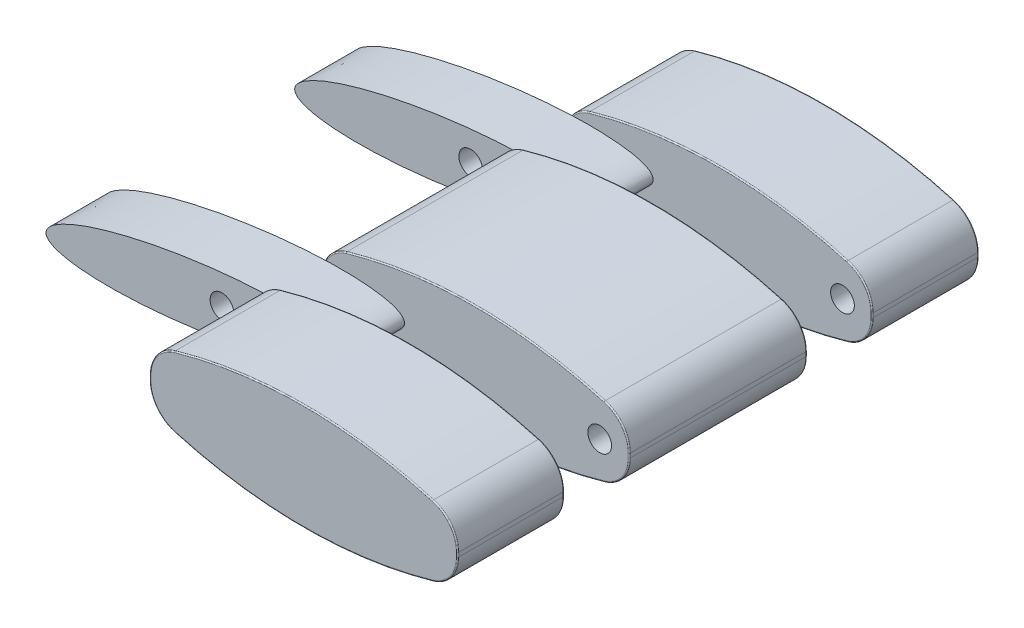
from build123d import *

# Parameters (mm, degrees)
BOSS_EXTRUDE1_DEPTH = 22
SKETCH2_W           = 20.821066257
SKETCH2_H           = 2.75
SKETCH2_W_2         = 22.326203578
CUT_EXTRUDE1_DEPTH  = 11
CUT_EXTRUDE2_START  = -0.5
SKETCH3_R           = 0.5
CUT_EXTRUDE2_DEPTH  = 21
FILLET1_R           = 0.05
FILLET2_R           = 0.05
FILLET3_R           = 0.05
SKETCH4_R           = 0.5
CUT_EXTRUDE3_DEPTH  = 30
BOSS_EXTRUDE2_START = -4.5
SKETCH6_RX          = 6.381317706
SKETCH6_RY          = 1.230977933
BOSS_EXTRUDE2_DEPTH = 2.5
BOSS_EXTRUDE3_START = -17.5
SKETCH6_2_RX        = 6.381317706
SKETCH6_2_RY        = 1.230977933
BOSS_EXTRUDE3_DEPTH = 2.5
SKETCH7_R           = 0.5
CUT_EXTRUDE6_DEPTH  = 22.5
SKETCH9_R           = 0.642655751
BOSS_EXTRUDE4_DEPTH = 0.5
SKETCH10_R          = 0.749250698
BOSS_EXTRUDE5_DEPTH = 0.5


with BuildPart() as part:
    # Sketch1 → Boss-Extrude1 (new body)
    with BuildSketch(Plane.XY):
        with BuildLine():
            Line((-6.5, 0.089598011), (-6.5, -0.089598011))
            ThreePointArc((-6.5, -0.089598011), (-6.208135141, -0.962078954), (-5.450037249, -1.483323307))
            ThreePointArc((-5.450037249, -1.483323307), (0, -2.25), (5.450037249, -1.483323307))
            ThreePointArc((5.450037249, -1.483323307), (6.208135141, -0.962078954), (6.5, -0.089598011))
            Line((6.5, -0.089598011), (6.5, 0.089598011))
            ThreePointArc((6.5, 0.089598011), (6.208135141, 0.962078954), (5.450037249, 1.483323307))
            ThreePointArc((5.450037249, 1.483323307), (0, 2.25), (-5.450037249, 1.483323307))
            ThreePointArc((-5.450037249, 1.483323307), (-6.208135141, 0.962078954), (-6.5, 0.089598011))
        make_face()
    extrude(amount=BOSS_EXTRUDE1_DEPTH)

    # Sketch2 → Cut-Extrude1 (cut, symmetric)
    with BuildSketch(Plane(origin=(0, 0, 0), x_dir=(1, 0, 0), z_dir=(0, 1, 0))):
        with Locations((-0.407641358, -5.875)):
            Rectangle(SKETCH2_W, SKETCH2_H)
        with Locations((1.37970921, -16.125)):
            Rectangle(SKETCH2_W_2, SKETCH2_H)
    extrude(amount=CUT_EXTRUDE1_DEPTH, both=True, mode=Mode.SUBTRACT)


with BuildPart() as cut_extrude1_piece_1:
    # of the separate pieces the step leaves, piece 1, a body of its own (cut_extrude1_pieces)
    add(part.part.solids().sort_by_distance((6.5, -0.089598011, 7.25))[0])


with BuildPart() as cut_extrude1_piece_2:
    # of the separate pieces the step leaves, piece 2, a body of its own (cut_extrude1_pieces)
    add(part.part.solids().sort_by_distance((6.5, -0.089598011, 17.5))[0])


with BuildPart() as cut_extrude1_piece_3:
    # of the separate pieces the step leaves, piece 3, a body of its own (cut_extrude1_pieces)
    add(part.part.solids().sort_by_distance((5.450037249, -1.483323307, 0))[0])


with BuildPart() as cut_extrude2_tool:
    # Sketch3 → Cut-Extrude2 (new body)
    with BuildSketch(Plane.XY.offset(22).offset(CUT_EXTRUDE2_START)):
        with Locations((5.25, 0)):
            Circle(SKETCH3_R)
        with Locations((-5.25, 0)):
            Circle(SKETCH3_R)
    extrude(amount=-CUT_EXTRUDE2_DEPTH)


with BuildPart() as cut_extrude1_piece_1_1:
    add(cut_extrude1_piece_1.part)

    # Cut-Extrude2: cut by cut_extrude2_tool
    add(cut_extrude2_tool.part, mode=Mode.SUBTRACT)

    # Fillet2
    fillet2_edges = [cut_extrude1_piece_1_1.edges().sort_by_distance(p)[0] for p in [
        (6.208135141, 0.962078954, 7.25),
        (6.5, 0, 7.25),
        (6.208135141, -0.962078954, 7.25),
        (0, -2.25, 7.25),
        (-6.208135141, -0.962078954, 7.25),
        (-6.5, 0, 7.25),
        (-6.208135141, 0.962078954, 7.25),
        (-6.208135141, 0.962078954, 14.75),
        (-6.5, 0, 14.75),
        (-6.208135141, -0.962078954, 14.75),
        (0, -2.25, 14.75),
        (6.208135141, -0.962078954, 14.75),
        (6.5, 0, 14.75),
        (6.208135141, 0.962078954, 14.75),
        (0, 2.25, 7.25),
        (0, 2.25, 14.75),
    ]]
    fillet(fillet2_edges, radius=FILLET2_R)


with BuildPart() as cut_extrude1_piece_2_1:
    add(cut_extrude1_piece_2.part)

    # Cut-Extrude2: cut by cut_extrude2_tool
    add(cut_extrude2_tool.part, mode=Mode.SUBTRACT)

    # Fillet1
    fillet1_edges = [cut_extrude1_piece_2_1.edges().sort_by_distance(p)[0] for p in [
        (6.208135141, 0.962078954, 17.5),
        (6.5, 0, 17.5),
        (6.208135141, -0.962078954, 17.5),
        (0, -2.25, 17.5),
        (-6.208135141, -0.962078954, 17.5),
        (-6.5, 0, 17.5),
        (-6.208135141, 0.962078954, 17.5),
        (6.5, 0, 22),
        (6.208135141, -0.962078954, 22),
        (0, -2.25, 22),
        (-6.208135141, -0.962078954, 22),
        (-6.5, 0, 22),
        (-6.208135141, 0.962078954, 22),
        (0, 2.25, 22),
        (6.208135141, 0.962078954, 22),
        (0, 2.25, 17.5),
    ]]
    fillet(fillet1_edges, radius=FILLET1_R)


with BuildPart() as cut_extrude1_piece_3_1:
    add(cut_extrude1_piece_3.part)

    # Cut-Extrude2: cut by cut_extrude2_tool
    add(cut_extrude2_tool.part, mode=Mode.SUBTRACT)

    # Fillet3
    fillet3_edges = [cut_extrude1_piece_3_1.edges().sort_by_distance(p)[0] for p in [
        (6.208135141, 0.962078954, 0),
        (6.5, 0, 0),
        (6.208135141, -0.962078954, 0),
        (0, -2.25, 0),
        (-6.208135141, -0.962078954, 0),
        (-6.5, 0, 0),
        (-6.208135141, 0.962078954, 0),
        (-6.5, 0, 4.5),
        (-6.208135141, -0.962078954, 4.5),
        (0, -2.25, 4.5),
        (6.208135141, -0.962078954, 4.5),
        (6.5, 0, 4.5),
        (6.208135141, 0.962078954, 4.5),
        (0, 2.25, 4.5),
        (0, 2.25, 0),
        (-6.208135141, 0.962078954, 4.5),
    ]]
    fillet(fillet3_edges, radius=FILLET3_R)


with BuildPart() as cut_extrude3_tool:
    # Sketch4 → Cut-Extrude3 (new, symmetric)
    with BuildSketch(Plane.XY.offset(4.5)):
        with Locations((5.25, 0)):
            Circle(SKETCH4_R)
    extrude(amount=CUT_EXTRUDE3_DEPTH, both=True)


with BuildPart() as cut_extrude1_piece_2_2:
    add(cut_extrude1_piece_2_1.part)

    # Cut-Extrude3: cut by cut_extrude3_tool
    add(cut_extrude3_tool.part, mode=Mode.SUBTRACT)

    # Sketch6 → Boss-Extrude2 (add)
    with BuildSketch(Plane.XY.offset(22).offset(BOSS_EXTRUDE2_START)):
        with Locations(Location((-9.058816325, -0.515837668), (0, 0, 8.239325628))):
            Ellipse(SKETCH6_RX, SKETCH6_RY)
    extrude(amount=-BOSS_EXTRUDE2_DEPTH)


with BuildPart() as cut_extrude1_piece_3_2:
    add(cut_extrude1_piece_3_1.part)

    # Cut-Extrude3: cut by cut_extrude3_tool
    add(cut_extrude3_tool.part, mode=Mode.SUBTRACT)

    # Sketch6_2 → Boss-Extrude3 (add)
    with BuildSketch(Plane.XY.offset(22).offset(BOSS_EXTRUDE3_START)):
        with Locations(Location((-9.058816325, -0.515837668), (0, 0, 8.239325628))):
            Ellipse(SKETCH6_2_RX, SKETCH6_2_RY)
    extrude(amount=BOSS_EXTRUDE3_DEPTH)


with BuildPart() as cut_extrude6_tool:
    # Sketch7 → Cut-Extrude6 (new body)
    with BuildSketch(Plane.XY.offset(17.5)):
        with Locations((-7.947567337, -0.377382917)):
            Circle(SKETCH7_R)
    extrude(amount=-CUT_EXTRUDE6_DEPTH)


with BuildPart() as cut_extrude1_piece_2_3:
    add(cut_extrude1_piece_2_2.part)

    # Cut-Extrude6: cut by cut_extrude6_tool
    add(cut_extrude6_tool.part, mode=Mode.SUBTRACT)

    # Sketch9 → Boss-Extrude4 (add)
    with BuildSketch(Plane.XY.offset(22)):
        with Locations((5.25, 0)):
            Circle(SKETCH9_R)
    extrude(amount=-BOSS_EXTRUDE4_DEPTH)


with BuildPart() as cut_extrude1_piece_3_3:
    add(cut_extrude1_piece_3_2.part)

    # Cut-Extrude6: cut by cut_extrude6_tool
    add(cut_extrude6_tool.part, mode=Mode.SUBTRACT)

    # Sketch10 → Boss-Extrude5 (add)
    with BuildSketch(Plane(origin=(0, 0, 0), x_dir=(-1, 0, 0), z_dir=(0, 0, -1))):
        with Locations((-5.25, 0)):
            Circle(SKETCH10_R)
    extrude(amount=-BOSS_EXTRUDE5_DEPTH)


solid = Compound([cut_extrude1_piece_1_1.part, cut_extrude1_piece_2_3.part, cut_extrude1_piece_3_3.part])
